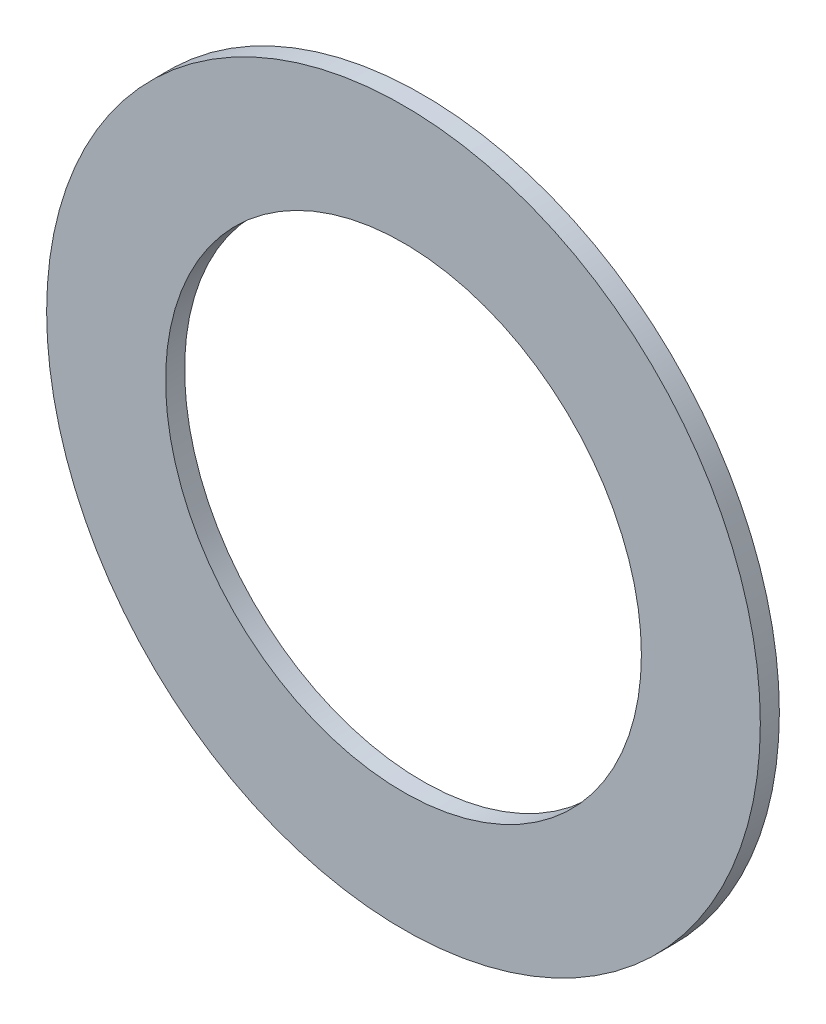
from build123d import *

# Parameters (mm, degrees)
SKETCH1_R           = 4.7625
SKETCH1_R_2         = 3.175
BOSS_EXTRUDE1_DEPTH = 0.254


with BuildPart() as part:
    # Sketch1 → Boss-Extrude1 (new body)
    with BuildSketch(Plane.XY):
        Circle(SKETCH1_R)
        Circle(SKETCH1_R_2, mode=Mode.SUBTRACT)
    extrude(amount=BOSS_EXTRUDE1_DEPTH)


solid = part.part
